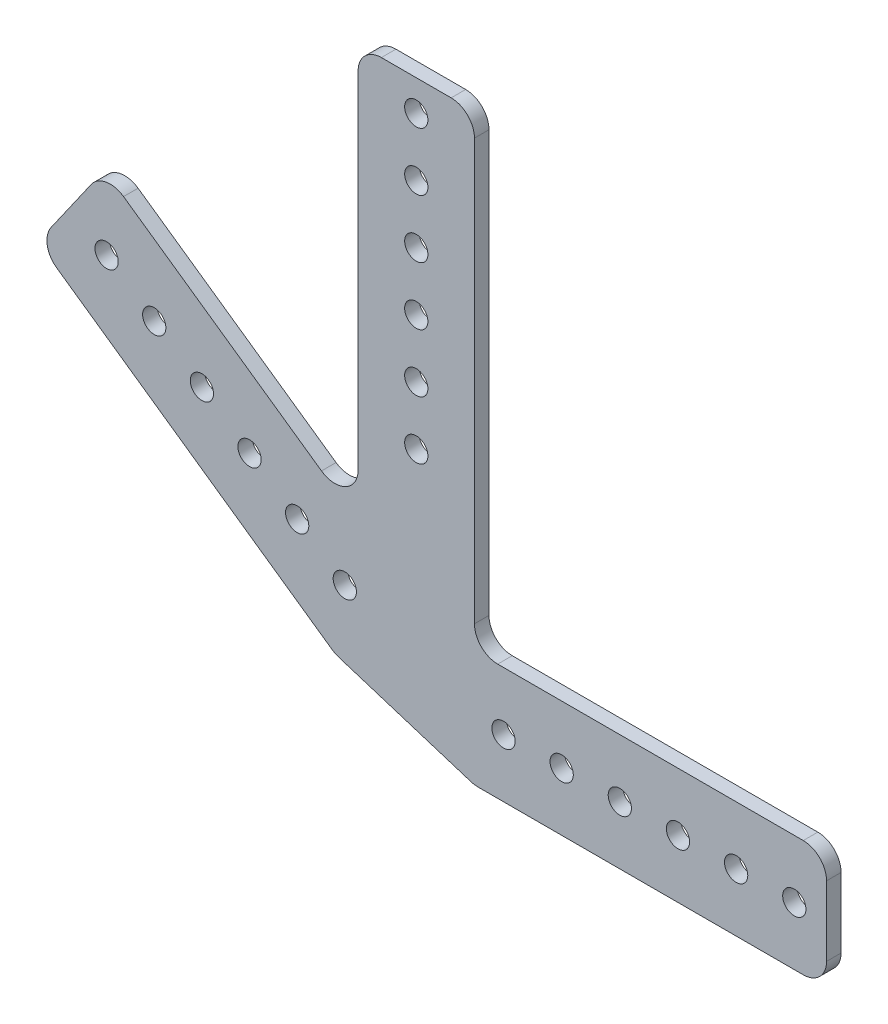
from build123d import *

# Parameters (mm, degrees)
BOSS_EXTRUDE1_DEPTH     = 3.175
CUT_EXTRUDE5_START      = 3.175
SKETCH3_R               = 2.54
CUT_EXTRUDE5_DEPTH      = 4.175
CUT_EXTRUDE5_DEPTH_BACK = 4.175


with BuildPart() as part:
    # Sketch2 → Boss-Extrude1 (new body)
    with BuildSketch(Plane.XY):
        with BuildLine():
            Line((-20.32, 127.404287689), (-5.08, 127.404287689))
            ThreePointArc((-5.08, 127.404287689), (-1.487897552, 125.916390137), (0, 122.324287689))
            Line((0, 122.324287689), (0, 50.8))
            Line((0, 50.8), (0, 30.48))
            ThreePointArc((0, 30.48), (1.487897552, 26.887897552), (5.08, 25.4))
            Line((5.08, 25.4), (71.811597359, 25.4))
            ThreePointArc((71.811597359, 25.4), (75.403699807, 23.912102448), (76.891597359, 20.32))
            Line((76.891597359, 20.32), (76.891597359, 5.08))
            ThreePointArc((76.891597359, 5.08), (75.403699807, 1.487897552), (71.811597359, 0))
            Line((71.811597359, 0), (0.781886783, 0))
            ThreePointArc((0.781886783, 0), (0.009099981, 0.059123527), (-0.745698678, 0.23511789))
            Line((-0.745698678, 0.23511789), (-29.641953026, 9.346071889))
            ThreePointArc((-29.641953026, 9.346071889), (-30.36119411, 9.634840472), (-31.028135861, 10.029661614))
            Line((-31.028135861, 10.029661614), (-91.189980426, 52.155438691))
            ThreePointArc((-91.189980426, 52.155438691), (-93.279035515, 55.434598334), (-92.437504515, 59.230499373))
            Line((-92.437504515, 59.230499373), (-83.696199625, 71.714376528))
            ThreePointArc((-83.696199625, 71.714376528), (-80.417039982, 73.803431616), (-76.621138943, 72.961900616))
            Line((-76.621138943, 72.961900616), (-33.393768297, 42.693769833))
            ThreePointArc((-33.393768297, 42.693769833), (-28.134317045, 42.349047185), (-25.4, 46.855062218))
            Line((-25.4, 46.855062218), (-25.4, 122.324287689))
            ThreePointArc((-25.4, 122.324287689), (-23.912102448, 125.916390137), (-20.32, 127.404287689))
        make_face()
    extrude(amount=BOSS_EXTRUDE1_DEPTH)

    # Sketch3 → Cut-Extrude5 (cut, two sides)
    with BuildSketch(Plane.XY.offset(CUT_EXTRUDE5_START)) as cut_extrude5_sk:
        with Locations((-12.7, 57.15)):
            Circle(SKETCH3_R)
        with Locations((6.35, 12.7)):
            Circle(SKETCH3_R)
        with Locations((-28.304846444, 23.626631112)):
            Circle(SKETCH3_R)
        with Locations((-38.708077406, 30.911051854)):
            Circle(SKETCH3_R)
        with Locations((-49.111308369, 38.195472596)):
            Circle(SKETCH3_R)
        with Locations((-59.514539331, 45.479893337)):
            Circle(SKETCH3_R)
        with Locations((-69.917770294, 52.764314079)):
            Circle(SKETCH3_R)
        with Locations((-80.321001256, 60.048734821)):
            Circle(SKETCH3_R)
        with Locations((-12.7, 69.85)):
            Circle(SKETCH3_R)
        with Locations((-12.7, 82.55)):
            Circle(SKETCH3_R)
        with Locations((-12.7, 95.25)):
            Circle(SKETCH3_R)
        with Locations((-12.7, 107.95)):
            Circle(SKETCH3_R)
        with Locations((-12.7, 120.65)):
            Circle(SKETCH3_R)
        with Locations((19.05, 12.7)):
            Circle(SKETCH3_R)
        with Locations((31.75, 12.7)):
            Circle(SKETCH3_R)
        with Locations((44.45, 12.7)):
            Circle(SKETCH3_R)
        with Locations((57.15, 12.7)):
            Circle(SKETCH3_R)
        with Locations((69.85, 12.7)):
            Circle(SKETCH3_R)
    extrude(amount=CUT_EXTRUDE5_DEPTH, mode=Mode.SUBTRACT)
    extrude(cut_extrude5_sk.sketch, amount=-CUT_EXTRUDE5_DEPTH_BACK, mode=Mode.SUBTRACT)


solid = part.part
